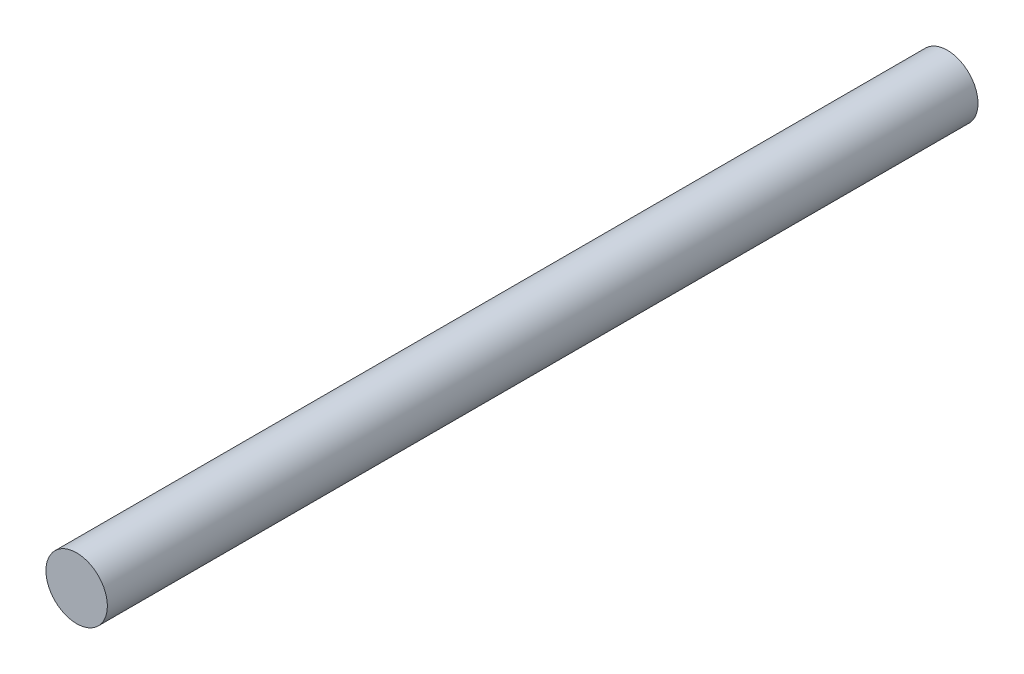
from build123d import *

# Parameters (mm, degrees)
CROQUIS1_R = 6.35


with BuildPart() as part:
    # Barrer1: sweep along a path in Croquis2
    with BuildLine(Plane(origin=(0, 0, 0), x_dir=(0, 0, -1), z_dir=(1, 0, 0))) as barrer1_path:
        Line((0, 0), (180, 0))
    # Croquis1 → Barrer1 (sweep)
    with BuildSketch(Plane.XY):
        Circle(CROQUIS1_R)
    sweep(path=barrer1_path.line)


solid = part.part
